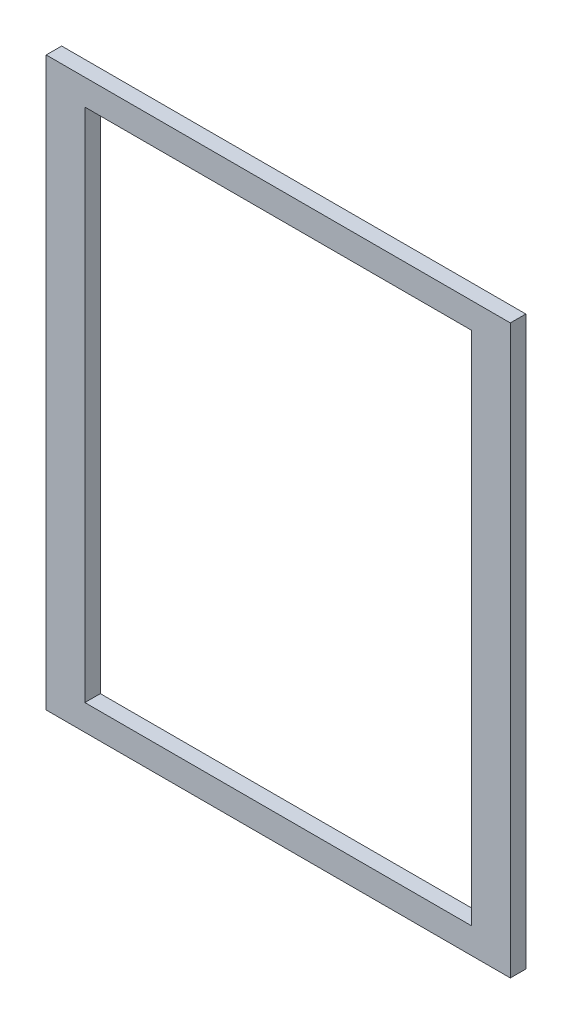
from build123d import *

# Parameters (mm, degrees)
SKETCH_1_W      = 180
SKETCH_1_H      = 220
SKETCH_1_W_2    = 150
SKETCH_1_H_2    = 200
EXTRUDE_1_DEPTH = 6


with BuildPart() as part:
    # Эскиз1 → Бобышка-Вытянуть1 (new body)
    with BuildSketch(Plane.XY):
        Rectangle(SKETCH_1_W, SKETCH_1_H)
        Rectangle(SKETCH_1_W_2, SKETCH_1_H_2, mode=Mode.SUBTRACT)
    extrude(amount=EXTRUDE_1_DEPTH)


solid = part.part
